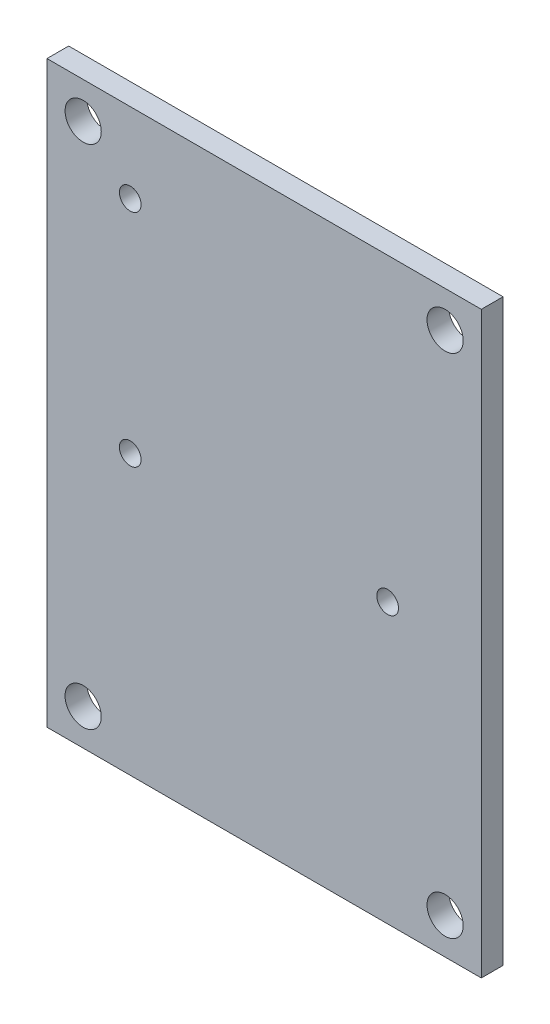
from build123d import *

# Parameters (mm, degrees)
SKETCH1_W           = 60
SKETCH1_H           = 80
BOSS_EXTRUDE1_DEPTH = 3
SKETCH2_R           = 2.5
CUT_EXTRUDE1_DEPTH  = 3
SKETCH3_R           = 1.5
CUT_EXTRUDE2_DEPTH  = 3


with BuildPart() as part:
    # Sketch1 → Boss-Extrude1 (new body)
    with BuildSketch(Plane.XY):
        Rectangle(SKETCH1_W, SKETCH1_H)
    extrude(amount=-BOSS_EXTRUDE1_DEPTH)

    # Sketch2 → Cut-Extrude1 (cut)
    with BuildSketch(Plane.XY):
        with Locations((-25, 35)):
            Circle(SKETCH2_R)
        with Locations((-25, -35)):
            Circle(SKETCH2_R)
        with Locations((25, -35)):
            Circle(SKETCH2_R)
        with Locations((25, 35)):
            Circle(SKETCH2_R)
    extrude(amount=-CUT_EXTRUDE1_DEPTH, mode=Mode.SUBTRACT)

    # Sketch3 → Cut-Extrude2 (cut)
    with BuildSketch(Plane.XY):
        with Locations((-18.5, 29)):
            Circle(SKETCH3_R)
        with Locations((-18.5, -1.48)):
            Circle(SKETCH3_R)
        with Locations((17.06, -1.48)):
            Circle(SKETCH3_R)
    extrude(amount=-CUT_EXTRUDE2_DEPTH, mode=Mode.SUBTRACT)


solid = part.part
